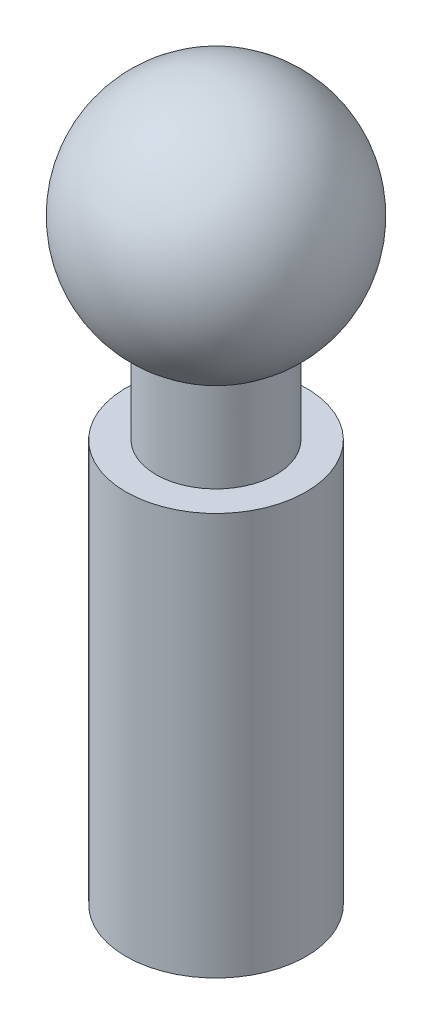
from build123d import *

# Parameters (mm, degrees)
SKETCH1_R           = 9.525
BOSS_EXTRUDE1_DEPTH = 42.545


with BuildPart() as part:
    # Sketch1 → Boss-Extrude1 (new body)
    with BuildSketch(Plane(origin=(0, 0, 0), x_dir=(1, 0, 0), z_dir=(0, 1, 0))):
        Circle(SKETCH1_R)
    extrude(amount=BOSS_EXTRUDE1_DEPTH)

    # Sketch2 → Revolve1 (revolve)
    with BuildSketch(Plane(origin=(0, 0, 0), x_dir=(0, 0, -1), z_dir=(1, 0, 0))):
        with BuildLine():
            Line((-6.35, 42.545), (-6.35, 52.07))
            ThreePointArc((-6.35, 52.07), (-12.267257994, 66.355524501), (0, 75.768522628))
            Line((0, 75.768522628), (0, 42.545))
            Line((0, 42.545), (-6.35, 42.545))
        make_face()
    revolve(axis=Axis((0, 75.768522628, 0), (0, -1, 0)))


solid = part.part
